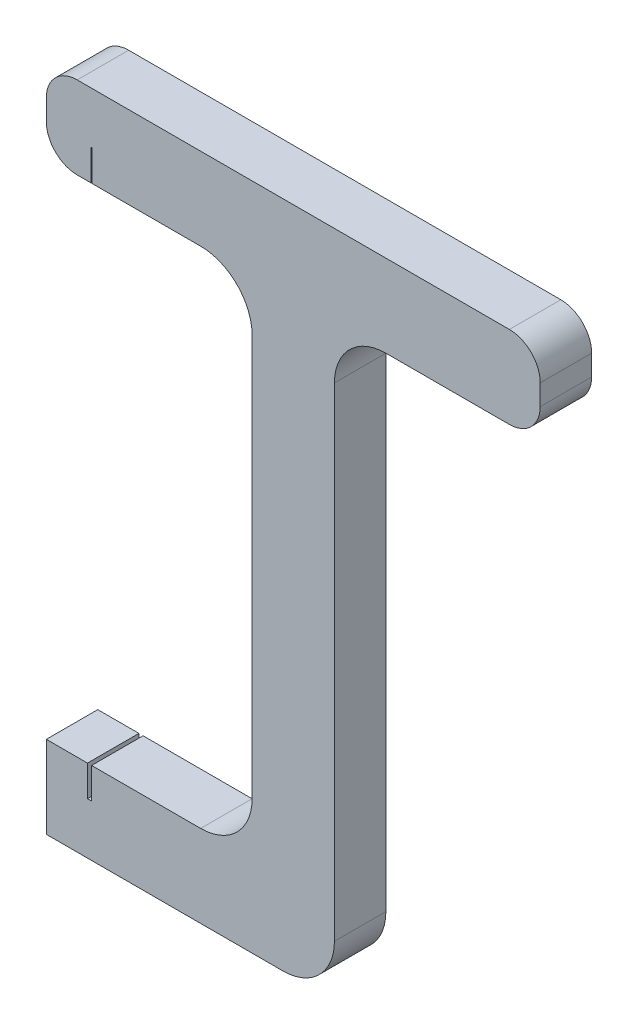
from build123d import *

# Parameters (mm, degrees)
BOSS_EXTRUDE1_DEPTH = 5
SKETCH2_W           = 0.4
SKETCH2_H           = 5
CUT_EXTRUDE1_DEPTH  = 3
SKETCH3_W           = 0.1
SKETCH3_H           = 5
CUT_EXTRUDE2_DEPTH  = 3
FILLET1_R           = 5
FILLET2_R           = 3


with BuildPart() as part:
    # Sketch1 → Boss-Extrude1 (new body)
    with BuildSketch(Plane.XY):
        Polygon((0, 65), (-28, 65), (-28, 57), (-8, 57), (-8, 8), (-28, 8), (-28, 0), (0, 0), (0, 57), (20, 57), (20, 65), align=None)
    extrude(amount=BOSS_EXTRUDE1_DEPTH)

    # Sketch2 → Cut-Extrude1 (cut)
    with BuildSketch(Plane(origin=(0, 8, 0), x_dir=(1, 0, 0), z_dir=(0, 1, 0))):
        with Locations((-23.8, -2.5)):
            Rectangle(SKETCH2_W, SKETCH2_H)
    extrude(amount=-CUT_EXTRUDE1_DEPTH, mode=Mode.SUBTRACT)

    # Sketch3 → Cut-Extrude2 (cut)
    with BuildSketch(Plane.XZ.offset(-57)):
        with Locations((-23.6, 2.5)):
            Rectangle(SKETCH3_W, SKETCH3_H)
    extrude(amount=-CUT_EXTRUDE2_DEPTH, mode=Mode.SUBTRACT)

    # Fillet1
    fillet1_edges = [part.edges().sort_by_distance(p)[0] for p in [
        (0, 0, 2.5),
        (-8, 8, 2.5),
        (-8, 57, 2.5),
        (0, 57, 2.5),
    ]]
    fillet(fillet1_edges, radius=FILLET1_R)

    # Fillet2
    fillet2_edges = [part.edges().sort_by_distance(p)[0] for p in [
        (-28, 57, 2.5),
        (-28, 65, 2.5),
        (20, 65, 2.5),
        (20, 57, 2.5),
    ]]
    fillet(fillet2_edges, radius=FILLET2_R)


solid = part.part
